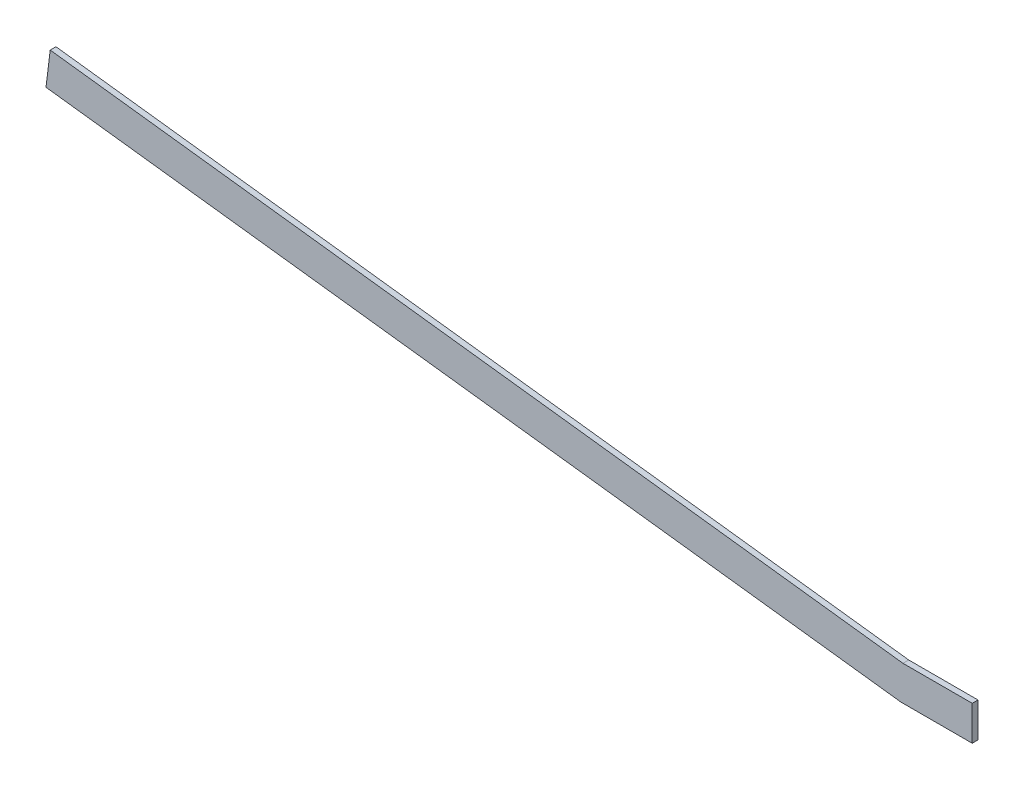
from build123d import *

# Parameters (mm, degrees)
BOSS_EXTRUDE1_DEPTH = 3.175


with BuildPart() as part:
    # Sketch1 → Boss-Extrude1 (new body, symmetric)
    with BuildSketch(Plane.XY):
        Polygon((0, 0), (-941.009074043, 115.541385962), (-936.365852059, 153.35739434), (2.330295828, 38.1), (78.530295828, 38.1), (78.530295828, 0), align=None)
    extrude(amount=BOSS_EXTRUDE1_DEPTH, both=True)


solid = part.part
